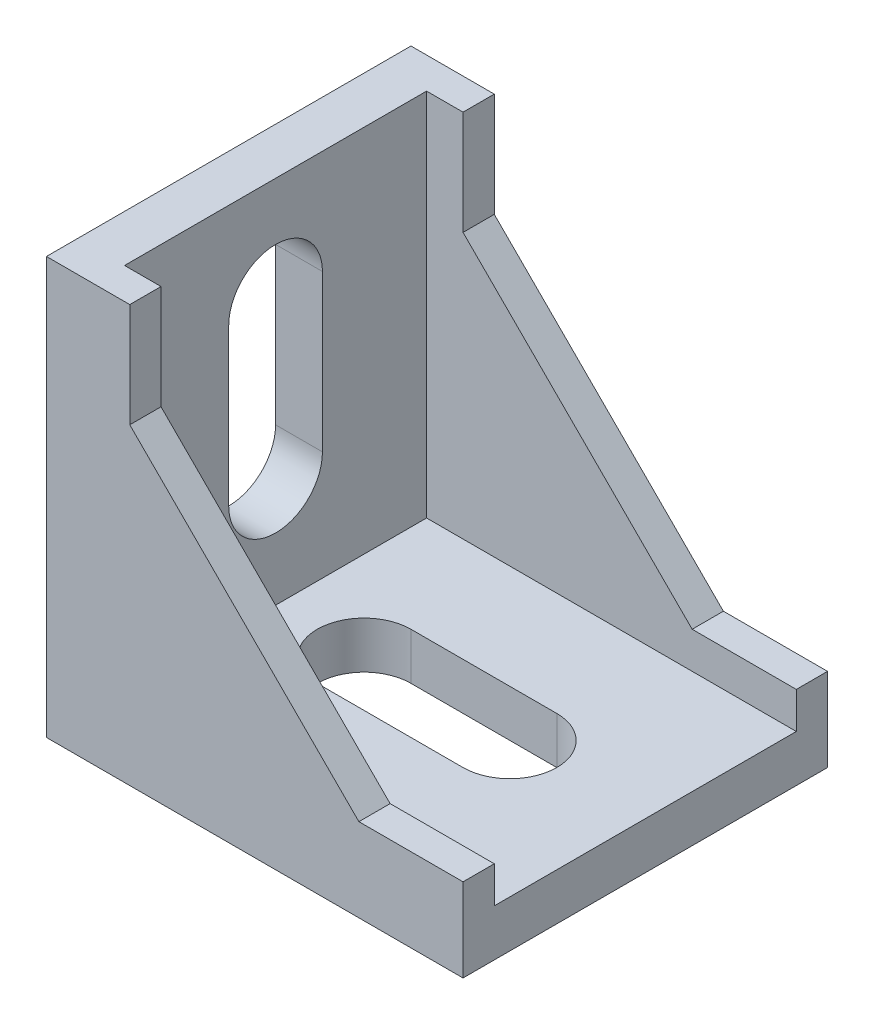
from build123d import *

# Parameters (mm, degrees)
EXTRUDE_1_DEPTH     = 17.5
CUT_EXTRUDE_1_DEPTH = 14.5
CUT_EXTRUDE_2_REACH = 42
CUT_EXTRUDE_3_REACH = 42


with BuildPart() as part:
    # 草图1 → 凸台-拉伸1 (new body, symmetric)
    with BuildSketch(Plane.XY):
        Polygon((0, 40), (0, 0), (40, 0), (40, 8), (30, 8), (8, 30), (8, 40), align=None)
    extrude(amount=EXTRUDE_1_DEPTH, both=True)

    # 草图2 → 切除-拉伸1 (cut, symmetric)
    with BuildSketch(Plane.XY):
        Polygon((4.5, 40), (4.5, 4.5), (40, 4.5), (40, 8), (8, 40), align=None)
    extrude(amount=CUT_EXTRUDE_1_DEPTH, both=True, mode=Mode.SUBTRACT)

    # 草图3 → 切除-拉伸2 (cut, up to next)
    with BuildSketch(Plane.XZ, mode=Mode.PRIVATE) as cut_extrude_2_sk1:
        with BuildLine():
            Line((13, -4.5), (27, -4.5))
            ThreePointArc((27, -4.5), (31.5, 0), (27, 4.5))
            Line((27, 4.5), (13, 4.5))
            ThreePointArc((13, 4.5), (8.5, 0), (13, -4.5))
        make_face()
    cut_extrude_2_tool1 = extrude(cut_extrude_2_sk1.sketch, amount=-CUT_EXTRUDE_2_REACH, mode=Mode.PRIVATE) & part.part
    add(cut_extrude_2_tool1.solids().sort_by_distance((20, 0, 0))[0], mode=Mode.SUBTRACT)

    # 草图4 → 切除-拉伸3 (cut, up to next)
    with BuildSketch(Plane.ZY, mode=Mode.PRIVATE) as cut_extrude_3_sk1:
        with BuildLine():
            Line((4.5, 15), (4.5, 30))
            ThreePointArc((4.5, 30), (0, 34.5), (-4.5, 30))
            Line((-4.5, 30), (-4.5, 15))
            ThreePointArc((-4.5, 15), (0, 10.5), (4.5, 15))
        make_face()
    cut_extrude_3_tool1 = extrude(cut_extrude_3_sk1.sketch, amount=-CUT_EXTRUDE_3_REACH, mode=Mode.PRIVATE) & part.part
    add(cut_extrude_3_tool1.solids().sort_by_distance((0, 22.5, 0))[0], mode=Mode.SUBTRACT)


solid = part.part
